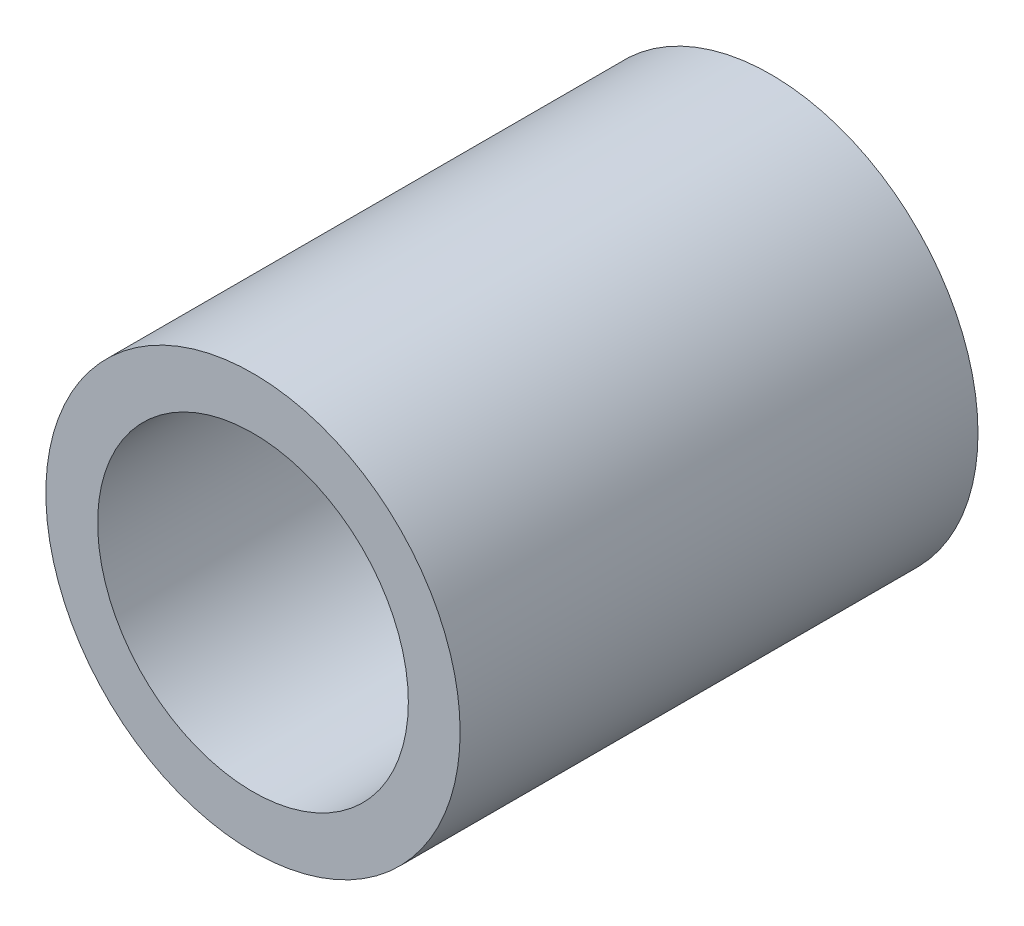
from build123d import *

# Parameters (mm, degrees)
SKETCH2_R           = 4
SKETCH2_R_2         = 3
BOSS_EXTRUDE1_DEPTH = 10


with BuildPart() as part:
    # Sketch2 → Boss-Extrude1 (new body)
    with BuildSketch(Plane.XY):
        Circle(SKETCH2_R)
        Circle(SKETCH2_R_2, mode=Mode.SUBTRACT)
    extrude(amount=BOSS_EXTRUDE1_DEPTH)


solid = part.part
